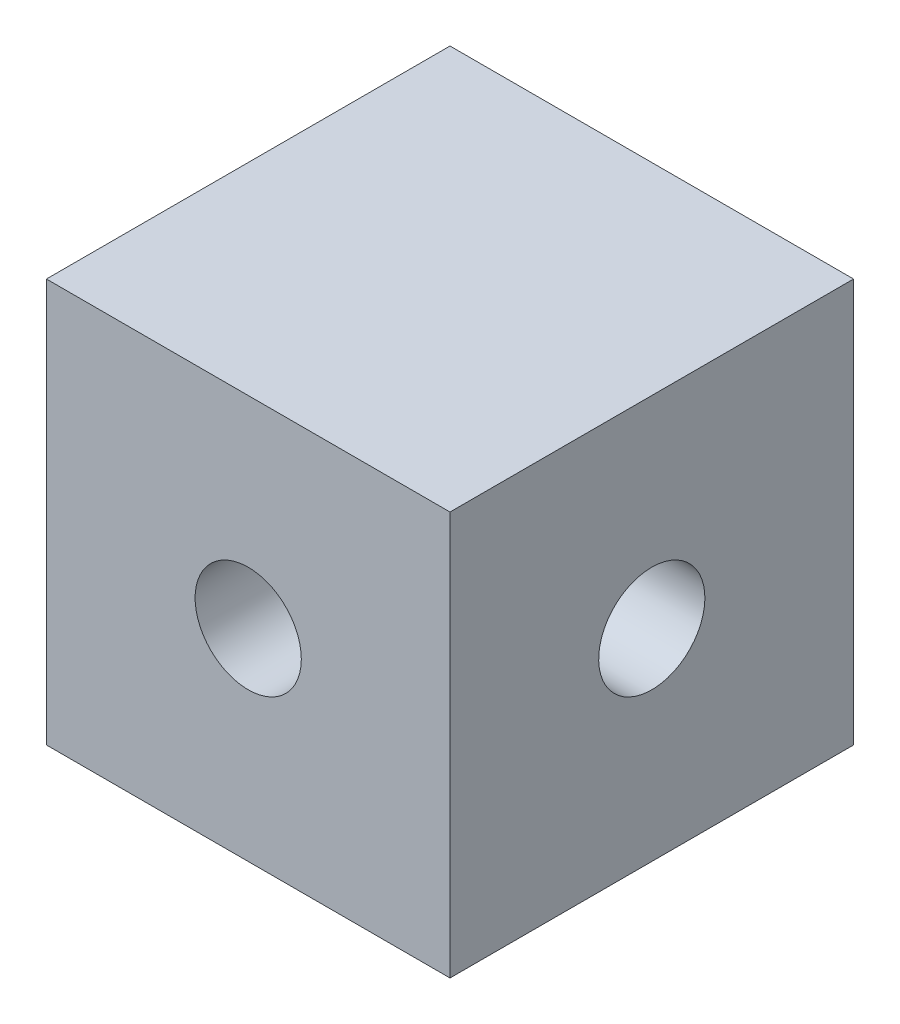
from build123d import *

# Parameters (mm, degrees)
SKETCH1_W           = 19
SKETCH1_H           = 19
BOSS_EXTRUDE1_DEPTH = 9.5
SKETCH2_R           = 2.5
CUT_EXTRUDE1_DEPTH  = 25
SKETCH3_R           = 2.5
CUT_EXTRUDE2_DEPTH  = 25


with BuildPart() as part:
    # Sketch1 → Boss-Extrude1 (new body, symmetric)
    with BuildSketch(Plane.XY):
        Rectangle(SKETCH1_W, SKETCH1_H)
    extrude(amount=BOSS_EXTRUDE1_DEPTH, both=True)

    # Sketch2 → Cut-Extrude1 (cut)
    with BuildSketch(Plane.XY.offset(9.5)):
        Circle(SKETCH2_R)
    extrude(amount=-CUT_EXTRUDE1_DEPTH, mode=Mode.SUBTRACT)

    # Sketch3 → Cut-Extrude2 (cut)
    with BuildSketch(Plane(origin=(9.5, 0, 0), x_dir=(0, 0, -1), z_dir=(1, 0, 0))):
        Circle(SKETCH3_R)
    extrude(amount=-CUT_EXTRUDE2_DEPTH, mode=Mode.SUBTRACT)


solid = part.part
